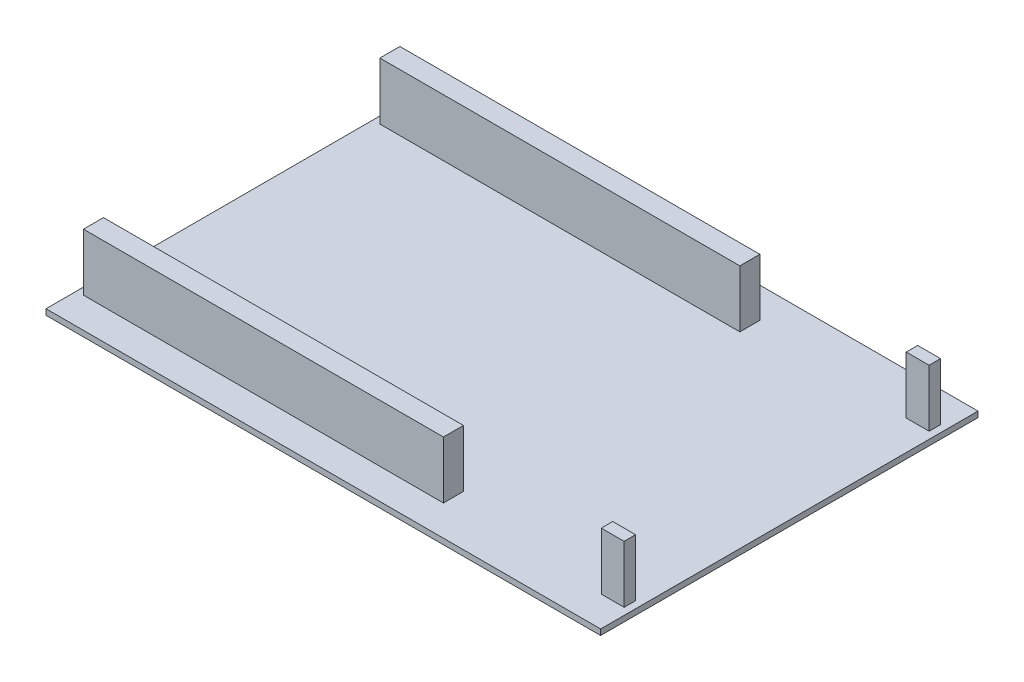
from build123d import *

# Parameters (mm, degrees)
SKETCH2_W           = 97
SKETCH2_H           = 66
BOSS_EXTRUDE2_DEPTH = 1
SKETCH3_W           = 62.96
SKETCH3_H           = 3.5
BOSS_EXTRUDE3_DEPTH = 10
SKETCH4_W           = 9
SKETCH4_H           = 6
BOSS_EXTRUDE4_DEPTH = 10
SKETCH5_W           = 4
SKETCH5_H           = 2
BOSS_EXTRUDE5_DEPTH = 10


with BuildPart() as part:
    # Sketch2 → Boss-Extrude2 (new body)
    with BuildSketch(Plane(origin=(0, 0, 0), x_dir=(1, 0, 0), z_dir=(0, 1, 0))):
        Rectangle(SKETCH2_W, SKETCH2_H)
    extrude(amount=BOSS_EXTRUDE2_DEPTH)

    # Sketch3 → Boss-Extrude3 (add)
    with BuildSketch(Plane(origin=(0, 1, 0), x_dir=(1, 0, 0), z_dir=(0, 1, 0))):
        with Locations((-15.8, 25.92)):
            Rectangle(SKETCH3_W, SKETCH3_H)
        with Locations((-15.8, -25.92)):
            Rectangle(SKETCH3_W, SKETCH3_H)
    extrude(amount=BOSS_EXTRUDE3_DEPTH)

    # Sketch4 → Boss-Extrude4 (add)
    with BuildSketch(Plane.XZ):
        with Locations((-47, 17.34)):
            Rectangle(SKETCH4_W, SKETCH4_H)
    extrude(amount=BOSS_EXTRUDE4_DEPTH)

    # Sketch5 → Boss-Extrude5 (add)
    with BuildSketch(Plane(origin=(0, 1, 0), x_dir=(1, 0, 0), z_dir=(0, 1, 0))):
        with Locations((45.28, 26.67)):
            Rectangle(SKETCH5_W, SKETCH5_H)
        with Locations((45.28, -26.67)):
            Rectangle(SKETCH5_W, SKETCH5_H)
    extrude(amount=BOSS_EXTRUDE5_DEPTH)


solid = part.part
